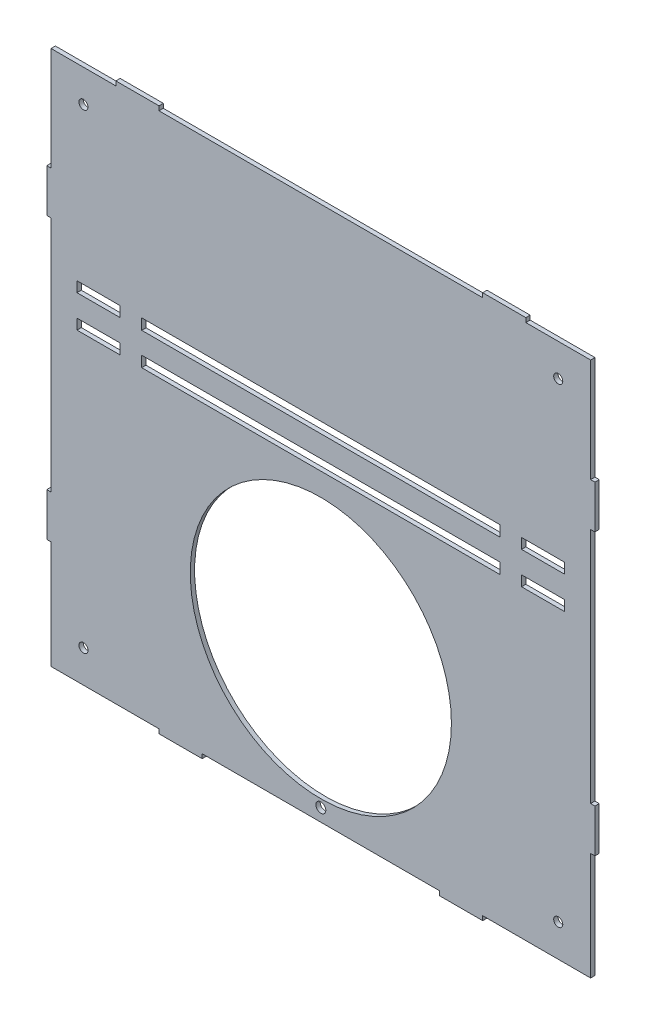
from build123d import *

# Parameters (mm, degrees)
SKETCH1_R           = 60.5
SKETCH1_R_2         = 2.3
BOSS_EXTRUDE1_DEPTH = 2
SKETCH3_W           = 20
SKETCH3_H           = 4.8
CUT_EXTRUDE1_DEPTH  = 5
SKETCH4_W           = 165.999999998
SKETCH4_H           = 5
CUT_EXTRUDE2_DEPTH  = 5
SKETCH5_R           = 2.1
CUT_EXTRUDE3_DEPTH  = 5
SKETCH6_W           = 30
SKETCH6_H           = 2
SKETCH6_W_2         = 150
CUT_EXTRUDE4_DEPTH  = 5
SKETCH7_R           = 2.1
CUT_EXTRUDE5_DEPTH  = 5


with BuildPart() as part:
    # Sketch1 → Boss-Extrude1 (new body)
    with BuildSketch(Plane.XY):
        Polygon((125.000000001, -69.9), (75.000000001, -69.9), (75.000000001, -71.9), (55.000000001, -71.9), (55.000000001, -69.9), (-54.999999999, -69.9), (-54.999999999, -71.9), (-74.999999999, -71.9), (-74.999999999, -69.9), (-124.999999999, -69.9), (-124.999999999, -19.9), (-126.999999999, -19.9), (-126.999999999, 0.1), (-124.999999999, 0.1), (-124.999999999, 110.1), (-126.999999999, 110.1), (-126.999999999, 130.1), (-124.999999999, 130.1), (-124.999999999, 180.1), (125.000000001, 180.1), (125.000000001, 130.1), (127.000000001, 130.1), (127.000000001, 110.1), (125.000000001, 110.1), (125.000000001, 0.1), (127.000000001, 0.1), (127.000000001, -19.9), (125.000000001, -19.9), align=None)
        Circle(SKETCH1_R, mode=Mode.SUBTRACT)
        with Locations((0, -64)):
            Circle(SKETCH1_R_2, mode=Mode.SUBTRACT)
    extrude(amount=BOSS_EXTRUDE1_DEPTH)

    # Sketch3 → Cut-Extrude1 (cut)
    with BuildSketch(Plane.XY.offset(2)):
        with Locations((-102.999999999, 88.505234687)):
            Rectangle(SKETCH3_W, SKETCH3_H)
        with Locations((-102.999999999, 73.505234687)):
            Rectangle(SKETCH3_W, SKETCH3_H)
    cut_extrude1 = extrude(amount=-CUT_EXTRUDE1_DEPTH, mode=Mode.SUBTRACT)

    # Mirror1: Cut-Extrude1 across plane
    add(cut_extrude1.mirror(Plane(origin=(0, 0, 0), x_dir=(0, 0, 1), z_dir=(1, 0, 0))), mode=Mode.SUBTRACT)

    # Sketch4 → Cut-Extrude2 (cut)
    with BuildSketch(Plane.XY.offset(2)):
        with Locations((0, 88.505234687)):
            Rectangle(SKETCH4_W, SKETCH4_H)
        with Locations((0, 73.505234687)):
            Rectangle(SKETCH4_W, SKETCH4_H)
    extrude(amount=-CUT_EXTRUDE2_DEPTH, mode=Mode.SUBTRACT)

    # Sketch5 → Cut-Extrude3 (cut)
    with BuildSketch(Plane.XY.offset(2)):
        with Locations((-109.999999999, -54.9)):
            Circle(SKETCH5_R)
        with Locations((110.000000001, -54.9)):
            Circle(SKETCH5_R)
    extrude(amount=-CUT_EXTRUDE3_DEPTH, mode=Mode.SUBTRACT)

    # Sketch6 → Cut-Extrude4 (cut)
    with BuildSketch(Plane.XY.offset(2)):
        with Locations((-109.999999999, 179.1)):
            Rectangle(SKETCH6_W, SKETCH6_H)
        with Locations((1e-09, 179.1)):
            Rectangle(SKETCH6_W_2, SKETCH6_H)
        with Locations((110.000000001, 179.1)):
            Rectangle(SKETCH6_W, SKETCH6_H)
    extrude(amount=-CUT_EXTRUDE4_DEPTH, mode=Mode.SUBTRACT)

    # Sketch7 → Cut-Extrude5 (cut)
    with BuildSketch(Plane.XY.offset(2)):
        with Locations((-109.999999999, 163.1)):
            Circle(SKETCH7_R)
        with Locations((110.000000001, 163.1)):
            Circle(SKETCH7_R)
    extrude(amount=-CUT_EXTRUDE5_DEPTH, mode=Mode.SUBTRACT)


solid = part.part
